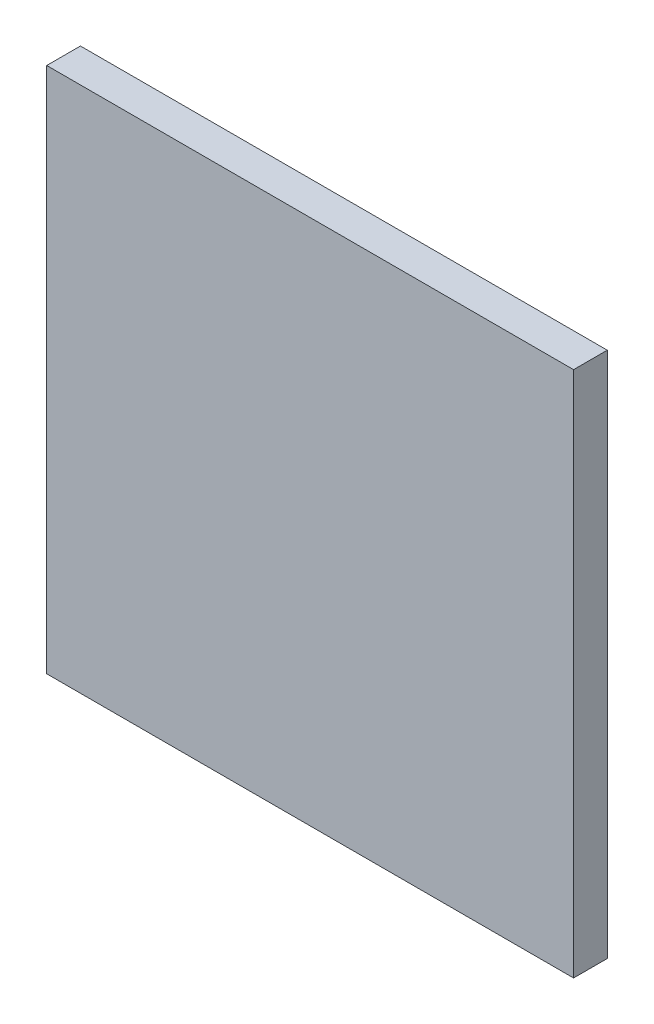
from build123d import *

# Parameters (mm, degrees)
SKETCH1_W           = 50
SKETCH1_H           = 50
BOSS_EXTRUDE1_DEPTH = 3.2


with BuildPart() as part:
    # Sketch1 → Boss-Extrude1 (new body)
    with BuildSketch(Plane(origin=(0, 0, 0), x_dir=(0, 1, 0), z_dir=(0, 0, 1))):
        Rectangle(SKETCH1_W, SKETCH1_H)
    extrude(amount=BOSS_EXTRUDE1_DEPTH)


solid = part.part
